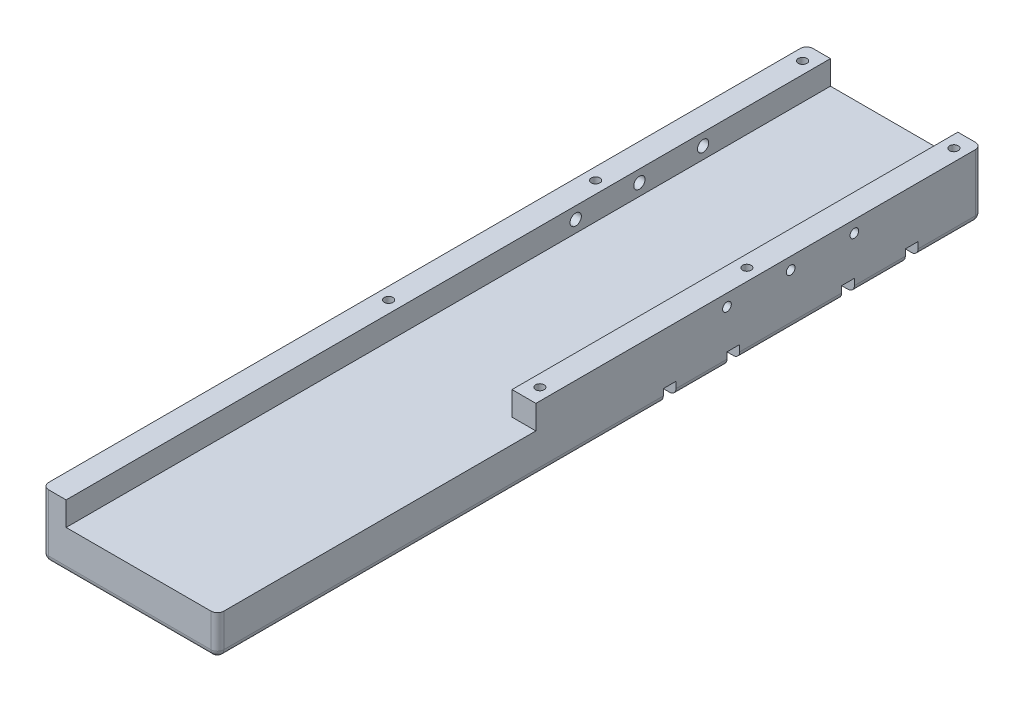
from build123d import *

# Parameters (mm, degrees)
SKETCH1_W                 = 69.85
SKETCH1_H                 = 304.8
BOSS_EXTRUDE1_DEPTH       = 25.4
FILLET1_R                 = 2.54
SKETCH2_W                 = 69.85
SKETCH2_H                 = 5.08
CUT_EXTRUDE1_DEPTH        = 5.08
SKETCH3_W                 = 50.8
SKETCH3_H                 = 304.8
CUT_EXTRUDE2_DEPTH        = 9.525
CUT_EXTRUDE3_REACH        = 71.85
SKETCH4_R                 = 2.2479
F_8_32_TAPPED_HOLE1_D     = 3.4544
F_8_32_TAPPED_HOLE1_DEPTH = 10.668
F_8_32_TAPPED_HOLE1_TIP   = 1.037806461
F_8_32_TAPPED_HOLE2_D     = 3.4544
F_8_32_TAPPED_HOLE2_DEPTH = 9.525
F_8_32_TAPPED_HOLE3_D     = 3.4544
F_8_32_TAPPED_HOLE3_DEPTH = 12.7
F_8_32_TAPPED_HOLE3_TIP   = 1.037806461
SKETCH16_W                = 9.525
SKETCH16_H                = 9.525
CUT_EXTRUDE4_DEPTH        = 127


with BuildPart() as part:
    # Sketch1 → Boss-Extrude1 (new body)
    with BuildSketch(Plane(origin=(0, 0, 0), x_dir=(1, 0, 0), z_dir=(0, 1, 0))):
        with Locations((34.925, 152.4)):
            Rectangle(SKETCH1_W, SKETCH1_H)
    extrude(amount=BOSS_EXTRUDE1_DEPTH)

    # Fillet1
    fillet1_edges = [part.edges().sort_by_distance(p)[0] for p in [
        (34.925, 0, -304.8),
        (69.85, 0, -152.4),
        (34.925, 0, 0),
        (0, 0, -152.4),
        (0, 12.7, -304.8),
        (69.85, 12.7, -304.8),
        (69.85, 12.7, 0),
        (0, 12.7, 0),
    ]]
    fillet(fillet1_edges, radius=FILLET1_R)

    # Sketch2 → Cut-Extrude1 (cut)
    with BuildSketch(Plane.XZ):
        with Locations((34.925, -180.34)):
            Rectangle(SKETCH2_W, SKETCH2_H)
        with Locations((34.925, -205.74)):
            Rectangle(SKETCH2_W, SKETCH2_H)
        with Locations((34.925, -251.46)):
            Rectangle(SKETCH2_W, SKETCH2_H)
        with Locations((34.925, -276.86)):
            Rectangle(SKETCH2_W, SKETCH2_H)
    extrude(amount=-CUT_EXTRUDE1_DEPTH, mode=Mode.SUBTRACT)

    # Sketch3 → Cut-Extrude2 (cut)
    with BuildSketch(Plane(origin=(0, 25.4, 0), x_dir=(1, 0, 0), z_dir=(0, 1, 0))):
        with Locations((34.925, 152.4)):
            Rectangle(SKETCH3_W, SKETCH3_H)
    extrude(amount=-CUT_EXTRUDE2_DEPTH, mode=Mode.SUBTRACT)

    # Sketch4 → Cut-Extrude3 (cut, up to next)
    with BuildSketch(Plane.ZY, mode=Mode.PRIVATE) as cut_extrude3_sk1:
        with Locations((-203.2, 20.6375)):
            Circle(SKETCH4_R)
    cut_extrude3_tool1 = extrude(cut_extrude3_sk1.sketch, amount=-CUT_EXTRUDE3_REACH, mode=Mode.PRIVATE) & part.part
    add(cut_extrude3_tool1.solids().sort_by_distance((0, 20.6375, -203.2))[0], mode=Mode.SUBTRACT)
    # Sketch4 → Cut-Extrude3 (cut, up to next)
    with BuildSketch(Plane.ZY, mode=Mode.PRIVATE) as cut_extrude3_sk2:
        with Locations((-228.6, 20.6375)):
            Circle(SKETCH4_R)
    cut_extrude3_tool2 = extrude(cut_extrude3_sk2.sketch, amount=-CUT_EXTRUDE3_REACH, mode=Mode.PRIVATE) & part.part
    add(cut_extrude3_tool2.solids().sort_by_distance((0, 20.6375, -228.6))[0], mode=Mode.SUBTRACT)
    # Sketch4 → Cut-Extrude3 (cut, up to next)
    with BuildSketch(Plane.ZY, mode=Mode.PRIVATE) as cut_extrude3_sk3:
        with Locations((-254, 20.6375)):
            Circle(SKETCH4_R)
    cut_extrude3_tool3 = extrude(cut_extrude3_sk3.sketch, amount=-CUT_EXTRUDE3_REACH, mode=Mode.PRIVATE) & part.part
    add(cut_extrude3_tool3.solids().sort_by_distance((0, 20.6375, -254))[0], mode=Mode.SUBTRACT)

    # #8-32 Tapped Hole1
    with Locations(Plane(origin=(0, 25.4, 0), x_dir=(1, 0, 0), z_dir=(0, 1, 0))):
        with Locations((65.0875, 298.45), (4.7625, 298.45), (65.0875, 215.9), (4.7625, 215.9), (65.0875, 133.35), (4.7625, 133.35)):
            Hole(F_8_32_TAPPED_HOLE1_D / 2, depth=F_8_32_TAPPED_HOLE1_DEPTH)
            with Locations((0, 0, -(F_8_32_TAPPED_HOLE1_DEPTH + F_8_32_TAPPED_HOLE1_TIP / 2))):  # 118° drill point
                Cone(0, F_8_32_TAPPED_HOLE1_D / 2, F_8_32_TAPPED_HOLE1_TIP, mode=Mode.SUBTRACT)

    # #8-32 Tapped Hole2
    with Locations(Plane(origin=(69.85, 0, 0), x_dir=(0, 0, -1), z_dir=(1, 0, 0))):
        with Locations((203.2, 20.6375), (228.6, 20.6375), (254, 20.6375)):
            Hole(F_8_32_TAPPED_HOLE2_D / 2, depth=F_8_32_TAPPED_HOLE2_DEPTH)

    # #8-32 Tapped Hole3
    with Locations(Plane(origin=(0, 0, 0), x_dir=(-1, 0, 0), z_dir=(0, -1, 0))):
        with Locations((-12.7, 289.56), (-57.15, 289.56), (-12.7, 264.16), (-57.15, 264.16), (-12.7, 238.76), (-57.15, 238.76), (-12.7, 218.44), (-57.15, 218.44), (-12.7, 193.04), (-57.15, 193.04), (-12.7, 167.64), (-57.15, 167.64)):
            Hole(F_8_32_TAPPED_HOLE3_D / 2, depth=F_8_32_TAPPED_HOLE3_DEPTH)
            with Locations((0, 0, -(F_8_32_TAPPED_HOLE3_DEPTH + F_8_32_TAPPED_HOLE3_TIP / 2))):  # 118° drill point
                Cone(0, F_8_32_TAPPED_HOLE3_D / 2, F_8_32_TAPPED_HOLE3_TIP, mode=Mode.SUBTRACT)

    # Sketch16 → Cut-Extrude4 (cut)
    with BuildSketch(Plane.XY):
        with Locations((65.0875, 20.6375)):
            Rectangle(SKETCH16_W, SKETCH16_H)
    extrude(amount=-CUT_EXTRUDE4_DEPTH, mode=Mode.SUBTRACT)


solid = part.part
